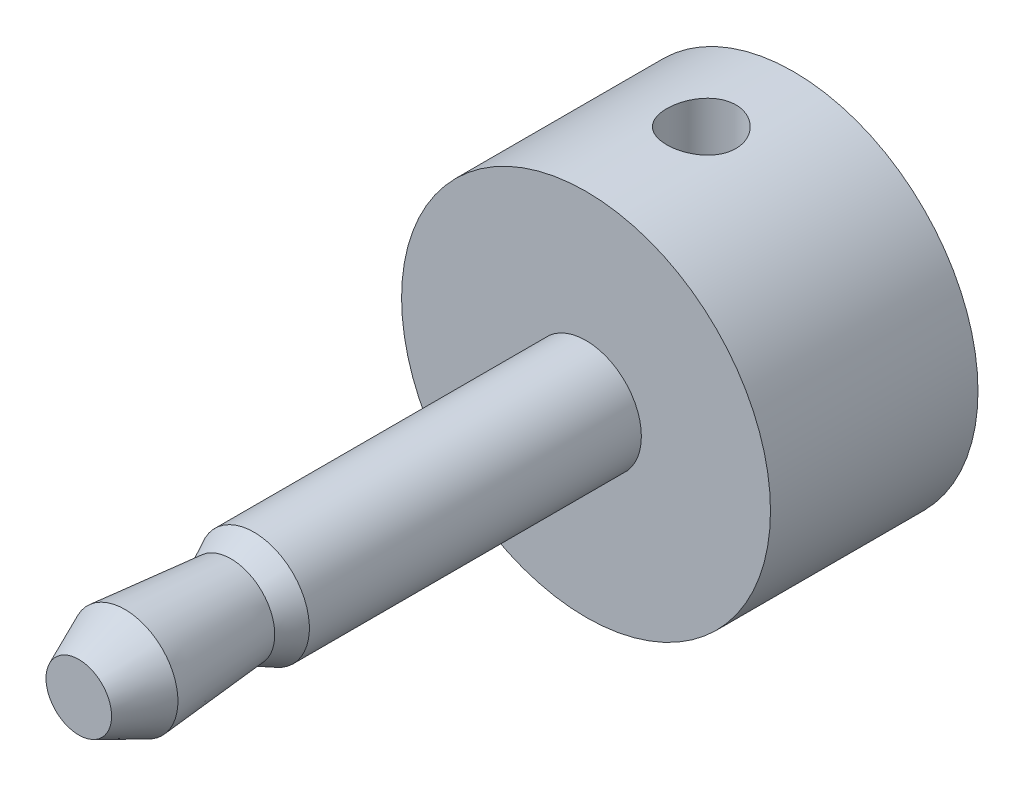
from build123d import *

# Parameters (mm, degrees)
SKETCH_1_R               = 4
EXTRUDE_1_DEPTH          = 5.5
SKETCH_2_R               = 1.2
EXTRUDE_2_DEPTH          = 11
SKETCH_6_R               = 0.75
CUT_EXTRUDE_1_DEPTH      = 5
CUT_EXTRUDE_1_DEPTH_BACK = 5
SKETCH_7_R               = 4
CUT_EXTRUDE_2_DEPTH      = 1


with BuildPart() as part:
    # ｽｹｯﾁ1 → ﾎﾞｽ - 押し出し1 (new body)
    with BuildSketch(Plane.XY):
        Circle(SKETCH_1_R)
    extrude(amount=EXTRUDE_1_DEPTH)

    # ｽｹｯﾁ2 → ﾎﾞｽ - 押し出し2 (add)
    with BuildSketch(Plane.XY.offset(5.5)):
        Circle(SKETCH_2_R)
    extrude(amount=EXTRUDE_2_DEPTH)

    # ｽｹｯﾁ4 → ｶｯﾄ - 回転1 (revolve, cut)
    with BuildSketch(Plane(origin=(0, 0, 0), x_dir=(1, 0, 0), z_dir=(0, 1, 0))):
        Polygon((1.2, -16.5), (0.711175277, -16.5), (1.15, -15.5), (0.95, -13.2), (1.2, -12.7), align=None)
    revolve(axis=Axis((0, 0, 12.792952675), (0, 0, 1)), mode=Mode.SUBTRACT)

    # ｽｹｯﾁ6 → ｶｯﾄ - 押し出し1 (cut, two sides)
    with BuildSketch(Plane(origin=(0, 0, 0), x_dir=(1, 0, 0), z_dir=(0, 1, 0))) as cut_extrude_1_sk:
        with Locations((0, -3)):
            Circle(SKETCH_6_R)
    extrude(amount=CUT_EXTRUDE_1_DEPTH, mode=Mode.SUBTRACT)
    extrude(cut_extrude_1_sk.sketch, amount=-CUT_EXTRUDE_1_DEPTH_BACK, mode=Mode.SUBTRACT)

    # ｽｹｯﾁ7 → ｶｯﾄ - 押し出し2 (cut)
    with BuildSketch(Plane(origin=(0, 0, 0), x_dir=(-1, 0, 0), z_dir=(0, 0, -1))):
        Circle(SKETCH_7_R)
    extrude(amount=-CUT_EXTRUDE_2_DEPTH, mode=Mode.SUBTRACT)


solid = part.part
